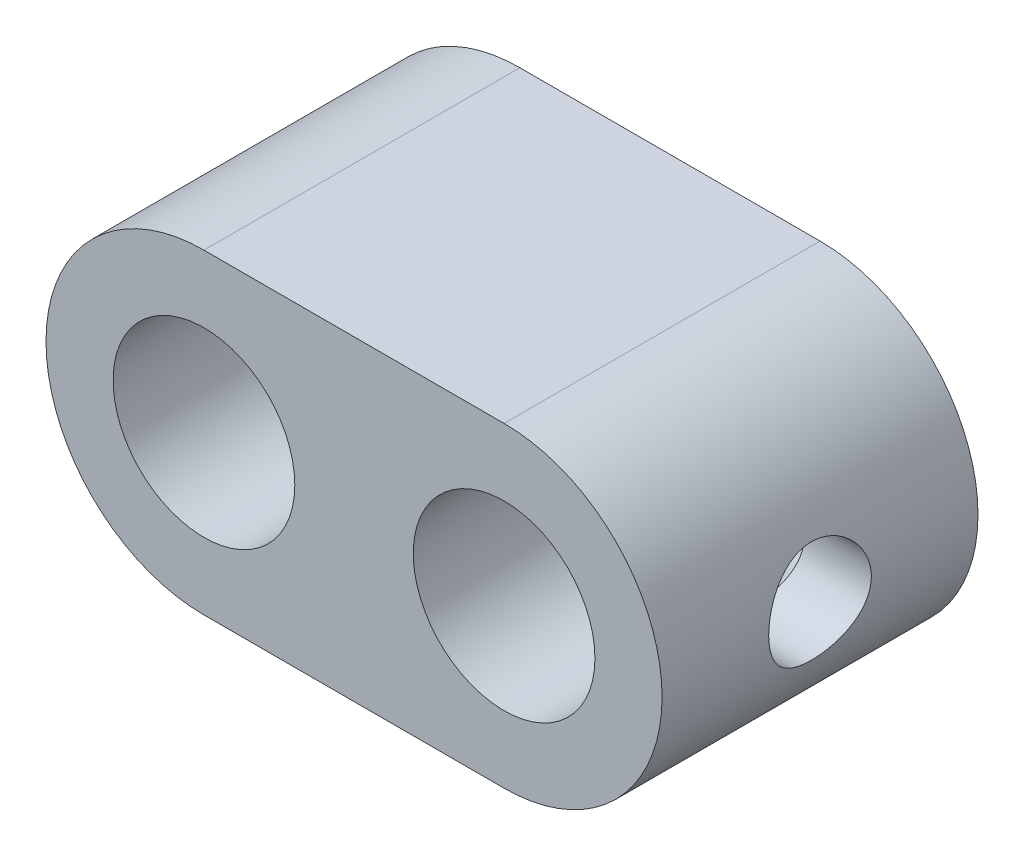
from build123d import *

# Parameters (mm, degrees)
SKETCH1_R               = 2.875
BOSS_EXTRUDE1_DEPTH     = 10
SKETCH2_R               = 1.625
CUT_EXTRUDE1_DEPTH      = 6
CUT_EXTRUDE1_DEPTH_BACK = 15.5


with BuildPart() as part:
    # Sketch1 → Boss-Extrude1 (new body)
    with BuildSketch(Plane.XY):
        with BuildLine():
            Line((0, -5), (-9.5, -5))
            ThreePointArc((-9.5, -5), (-14.5, 0), (-9.5, 5))
            Line((-9.5, 5), (0, 5))
            ThreePointArc((0, 5), (5, 0), (0, -5))
        make_face()
        Circle(SKETCH1_R, mode=Mode.SUBTRACT)
        with Locations((-9.5, 0)):
            Circle(SKETCH1_R, mode=Mode.SUBTRACT)
    extrude(amount=BOSS_EXTRUDE1_DEPTH)

    # Sketch2 → Cut-Extrude1 (cut, two sides)
    with BuildSketch(Plane(origin=(0, 0, 0), x_dir=(0, 0, -1), z_dir=(1, 0, 0))) as cut_extrude1_sk:
        with Locations((-5, 0)):
            Circle(SKETCH2_R)
    extrude(amount=CUT_EXTRUDE1_DEPTH, mode=Mode.SUBTRACT)
    extrude(cut_extrude1_sk.sketch, amount=-CUT_EXTRUDE1_DEPTH_BACK, mode=Mode.SUBTRACT)


solid = part.part
